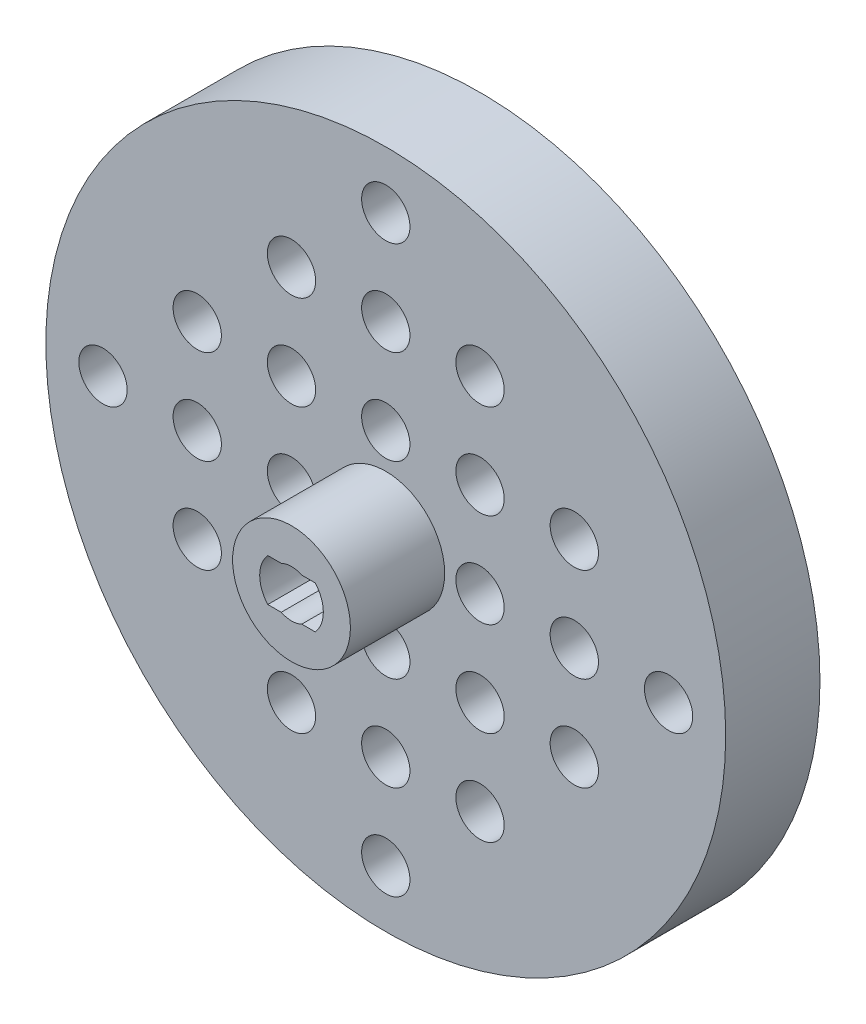
from build123d import *

# Parameters (mm, degrees)
EXTRUDE_1_DEPTH          = 4
EXTRUDE_1_DEPTH_BACK     = 4
SKETCH_1_R               = 28.85
SKETCH_2_R               = 5
EXTRUDE_2_DEPTH          = 8
SKETCH_3_R               = 1.8
CUT_EXTRUDE_1_DEPTH      = 44.825164004
SKETCH_4_R               = 4
CUT_EXTRUDE_2_DEPTH      = 4
SKETCH_5_R               = 5
CUT_EXTRUDE_3_DEPTH      = 0.7
CUT_EXTRUDE_4_DEPTH      = 7.5
CUT_EXTRUDE_5_DEPTH      = 43.528167137
CUT_EXTRUDE_5_DEPTH_BACK = 43.528167137
SKETCH_7_R               = 2.05


with BuildPart() as part:
    # Эскиз1 → Бобышка-Вытянуть1 (new, two sides: drawn at the far end of the back side and taken through both)
    with BuildSketch(Plane.XY.offset(-EXTRUDE_1_DEPTH_BACK)):
        Circle(SKETCH_1_R)
    extrude(amount=EXTRUDE_1_DEPTH + EXTRUDE_1_DEPTH_BACK)

    # Эскиз2 → Бобышка-Вытянуть2 (add)
    with BuildSketch(Plane.XY.offset(4)):
        Circle(SKETCH_2_R)
    extrude(amount=EXTRUDE_2_DEPTH)

    # Эскиз3 → Вырез-Вытянуть1 (cut, through all)
    with BuildSketch(Plane.XY.offset(12)):
        Circle(SKETCH_3_R)
    extrude(amount=-CUT_EXTRUDE_1_DEPTH, mode=Mode.SUBTRACT)

    # Эскиз4 → Вырез-Вытянуть2 (cut)
    with BuildSketch(Plane(origin=(0, 0, -4), x_dir=(-1, 0, 0), z_dir=(0, 0, -1))):
        Circle(SKETCH_4_R)
    extrude(amount=-CUT_EXTRUDE_2_DEPTH, mode=Mode.SUBTRACT)

    # Эскиз5 → Вырез-Вытянуть3 (cut)
    with BuildSketch(Plane(origin=(0, 0, -4), x_dir=(-1, 0, 0), z_dir=(0, 0, -1))):
        Circle(SKETCH_5_R)
    extrude(amount=-CUT_EXTRUDE_3_DEPTH, mode=Mode.SUBTRACT)

    # Эскиз6 → Вырез-Вытянуть4 (cut)
    with BuildSketch(Plane.XY.offset(12)):
        with BuildLine():
            ThreePointArc((2.01246118, -1.8), (2.7, 0), (2.01246118, 1.8))
            Line((2.01246118, 1.8), (0.871779789, 1.8))
            ThreePointArc((0.871779789, 1.8), (0, 2), (-0.871779789, 1.8))
            Line((-0.871779789, 1.8), (-2.01246118, 1.8))
            ThreePointArc((-2.01246118, 1.8), (-2.7, 0), (-2.01246118, -1.8))
            Line((-2.01246118, -1.8), (-0.871779789, -1.8))
            ThreePointArc((-0.871779789, -1.8), (0, -2), (0.871779789, -1.8))
            Line((0.871779789, -1.8), (2.01246118, -1.8))
        make_face()
    extrude(amount=-CUT_EXTRUDE_4_DEPTH, mode=Mode.SUBTRACT)

    # Эскиз7 → Вырез-Вытянуть5 (cut, two sides: drawn at the far end of the back side and taken through both)
    with BuildSketch(Plane.XY.offset(-CUT_EXTRUDE_5_DEPTH_BACK)):
        with Locations((-24, 0)):
            Circle(SKETCH_7_R)
        with Locations((-16, 0)):
            Circle(SKETCH_7_R)
        with Locations((-8, 0)):
            Circle(SKETCH_7_R)
        with Locations((-8, 8)):
            Circle(SKETCH_7_R)
        with Locations((-16, 8)):
            Circle(SKETCH_7_R)
        with Locations((0, 8)):
            Circle(SKETCH_7_R)
        with Locations((0, 16)):
            Circle(SKETCH_7_R)
        with Locations((-8, 16)):
            Circle(SKETCH_7_R)
        with Locations((0, 24)):
            Circle(SKETCH_7_R)
        with Locations((0, -24)):
            Circle(SKETCH_7_R)
        with Locations((-8, -16)):
            Circle(SKETCH_7_R)
        with Locations((0, -16)):
            Circle(SKETCH_7_R)
        with Locations((0, -8)):
            Circle(SKETCH_7_R)
        with Locations((-16, -8)):
            Circle(SKETCH_7_R)
        with Locations((-8, -8)):
            Circle(SKETCH_7_R)
        with Locations((8, -8)):
            Circle(SKETCH_7_R)
        with Locations((16, -8)):
            Circle(SKETCH_7_R)
        with Locations((8, -16)):
            Circle(SKETCH_7_R)
        with Locations((8, 16)):
            Circle(SKETCH_7_R)
        with Locations((16, 8)):
            Circle(SKETCH_7_R)
        with Locations((8, 8)):
            Circle(SKETCH_7_R)
        with Locations((8, 0)):
            Circle(SKETCH_7_R)
        with Locations((16, 0)):
            Circle(SKETCH_7_R)
        with Locations((24, 0)):
            Circle(SKETCH_7_R)
    extrude(amount=CUT_EXTRUDE_5_DEPTH + CUT_EXTRUDE_5_DEPTH_BACK, mode=Mode.SUBTRACT)


solid = part.part
